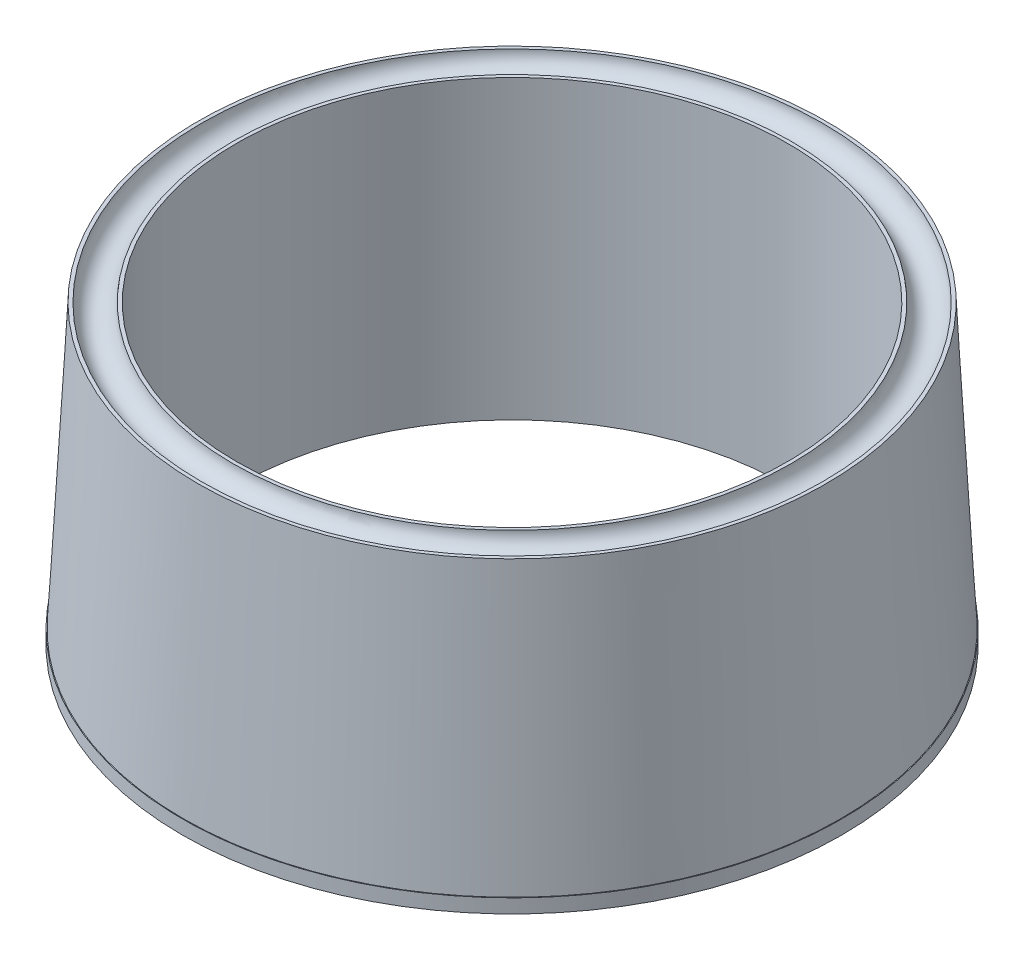
from build123d import *

# Parameters (mm, degrees)
SKETCH1_R            = 45
BOSS_EXTRUDE1_DEPTH  = 42.5
SKETCH2_R            = 39.5
CUT_EXTRUDE1_DEPTH   = 148
DRAFT2_ANGLE         = 3
CUT_EXTRUDE2_DEPTH   = 5
SKETCH7_R            = 47.22733062
BOSS_EXTRUDE2_DEPTH  = 2
SKETCH8_R            = 39.5
CUT_EXTRUDE3_DEPTH   = 66
CUT_EXTRUDE4_DEPTH   = 15
CUT_SWEEP1_PROFILE_R = 2.25


with BuildPart() as part:
    # Sketch1 → Boss-Extrude1 (new body)
    with BuildSketch(Plane(origin=(0, 0, 0), x_dir=(1, 0, 0), z_dir=(0, 1, 0))):
        Circle(SKETCH1_R)
    extrude(amount=BOSS_EXTRUDE1_DEPTH)

    # Sketch2 → Cut-Extrude1 (cut)
    with BuildSketch(Plane(origin=(0, 42.5, 0), x_dir=(1, 0, 0), z_dir=(0, 1, 0))):
        Circle(SKETCH2_R)
    extrude(amount=-CUT_EXTRUDE1_DEPTH, mode=Mode.SUBTRACT)

    # Draft2
    draft2_faces = [part.faces().sort_by_distance(p)[0] for p in [
        (-45, 21.25, 0),
    ]]
    draft(draft2_faces, Plane.ZX.offset(42.5), DRAFT2_ANGLE)

    # Sketch6 → Cut-Extrude2 (cut)
    with BuildSketch(Plane.XZ):
        Polygon((-24.581832655, 35.879719979), (-23.131832655, 35.042562088), (-21.681832655, 37.554035759), (-18.781832655, 37.554035759), (-18.781832655, 39.22835154), (-21.681832655, 40.902667321), (-24.581832655, 39.22835154), align=None)
        Polygon((18.781832655, 39.22835154), (18.781832655, 37.554035759), (21.681832655, 37.554035759), (23.131832655, 35.042562088), (24.581832655, 35.879719979), (24.581832655, 39.22835154), (21.681832655, 40.902667321), align=None)
        Polygon((43.36366531, 0), (41.91366531, -2.511473671), (43.36366531, -3.348631561), (46.26366531, -1.674315781), (46.26366531, 1.674315781), (43.36366531, 3.348631561), (41.91366531, 2.511473671), align=None)
        Polygon((21.681832655, -37.554035759), (18.781832655, -37.554035759), (18.781832655, -39.22835154), (21.681832655, -40.902667321), (24.581832655, -39.22835154), (24.581832655, -35.879719979), (23.131832655, -35.042562088), align=None)
        Polygon((-21.681832655, -37.554035759), (-23.131832655, -35.042562088), (-24.581832655, -35.879719979), (-24.581832655, -39.22835154), (-21.681832655, -40.902667321), (-18.781832655, -39.22835154), (-18.781832655, -37.554035759), align=None)
        Polygon((-41.91366531, -2.511473671), (-43.36366531, 0), (-41.91366531, 2.511473671), (-43.36366531, 3.348631561), (-46.26366531, 1.674315781), (-46.26366531, -1.674315781), (-43.36366531, -3.348631561), align=None)
        Polygon((-41.91366531, 2.511473671), (-43.36366531, 0), (-41.91366531, -2.511473671), (-40.46366531, -1.674315781), (-40.46366531, 1.674315781), align=None)
        Polygon((-21.681832655, 37.554035759), (-23.131832655, 35.042562088), (-21.681832655, 34.205404198), (-18.781832655, 35.879719979), (-18.781832655, 37.554035759), align=None)
        Polygon((21.681832655, 37.554035759), (18.781832655, 37.554035759), (18.781832655, 35.879719979), (21.681832655, 34.205404198), (23.131832655, 35.042562088), align=None)
        Polygon((40.46366531, -1.674315781), (41.91366531, -2.511473671), (43.36366531, 0), (41.91366531, 2.511473671), (40.46366531, 1.674315781), align=None)
        Polygon((18.781832655, -35.879719979), (18.781832655, -37.554035759), (21.681832655, -37.554035759), (23.131832655, -35.042562088), (21.681832655, -34.205404198), align=None)
        Polygon((-21.681832655, -34.205404198), (-23.131832655, -35.042562088), (-21.681832655, -37.554035759), (-18.781832655, -37.554035759), (-18.781832655, -35.879719979), align=None)
    extrude(amount=-CUT_EXTRUDE2_DEPTH, mode=Mode.SUBTRACT)

    # Sketch7 → Boss-Extrude2 (add)
    with BuildSketch(Plane.XZ):
        Circle(SKETCH7_R)
    extrude(amount=-BOSS_EXTRUDE2_DEPTH)

    # Sketch8 → Cut-Extrude3 (cut)
    with BuildSketch(Plane(origin=(0, 2, 0), x_dir=(1, 0, 0), z_dir=(0, 1, 0))):
        Circle(SKETCH8_R)
    extrude(amount=-CUT_EXTRUDE3_DEPTH, mode=Mode.SUBTRACT)

    # Sketch9 → Cut-Extrude4 (cut)
    with BuildSketch(Plane.XZ):
        with BuildLine():
            Line((-42.51, 1.472243186), (-43.36, 0))
            Line((-43.36, 0), (-42.51, -1.472243186))
            ThreePointArc((-42.51, -1.472243186), (-41.887756814, -0.85), (-41.66, 0))
            ThreePointArc((-41.66, 0), (-41.887756814, 0.85), (-42.51, 1.472243186))
        make_face()
        with BuildLine():
            Line((-42.51, -1.472243186), (-43.36, 0))
            Line((-43.36, 0), (-42.51, 1.472243186))
            ThreePointArc((-42.51, 1.472243186), (-45.06, 0), (-42.51, -1.472243186))
        make_face()
        with BuildLine():
            ThreePointArc((-19.98, 37.550861508), (-22.53, 39.023104695), (-22.53, 36.078618322))
            Line((-22.53, 36.078618322), (-21.68, 37.550861508))
            Line((-21.68, 37.550861508), (-19.98, 37.550861508))
        make_face()
        with BuildLine():
            Line((-21.68, 37.550861508), (-22.53, 36.078618322))
            ThreePointArc((-22.53, 36.078618322), (-20.83, 36.078618322), (-19.98, 37.550861508))
            Line((-19.98, 37.550861508), (-21.68, 37.550861508))
        make_face()
        with BuildLine():
            ThreePointArc((23.38, 37.550861508), (21.68, 39.250861508), (19.98, 37.550861508))
            Line((19.98, 37.550861508), (21.68, 37.550861508))
            Line((21.68, 37.550861508), (22.53, 36.078618322))
            ThreePointArc((22.53, 36.078618322), (23.152243186, 36.700861508), (23.38, 37.550861508))
        make_face()
        with BuildLine():
            Line((21.68, 37.550861508), (19.98, 37.550861508))
            ThreePointArc((19.98, 37.550861508), (20.83, 36.078618322), (22.53, 36.078618322))
            Line((22.53, 36.078618322), (21.68, 37.550861508))
        make_face()
        with BuildLine():
            ThreePointArc((42.51, 1.472243186), (41.66, 0), (42.51, -1.472243186))
            Line((42.51, -1.472243186), (43.36, 0))
            Line((43.36, 0), (42.51, 1.472243186))
        make_face()
        with BuildLine():
            Line((43.36, 0), (42.51, -1.472243186))
            ThreePointArc((42.51, -1.472243186), (44.21, -1.472243186), (45.06, 0))
            ThreePointArc((45.06, 0), (44.21, 1.472243186), (42.51, 1.472243186))
            Line((42.51, 1.472243186), (43.36, 0))
        make_face()
        with BuildLine():
            ThreePointArc((22.53, -36.078618322), (20.83, -36.078618322), (19.98, -37.550861508))
            Line((19.98, -37.550861508), (21.68, -37.550861508))
            Line((21.68, -37.550861508), (22.53, -36.078618322))
        make_face()
        with BuildLine():
            Line((21.68, -37.550861508), (19.98, -37.550861508))
            ThreePointArc((19.98, -37.550861508), (21.68, -39.250861508), (23.38, -37.550861508))
            ThreePointArc((23.38, -37.550861508), (23.152243186, -36.700861508), (22.53, -36.078618322))
            Line((22.53, -36.078618322), (21.68, -37.550861508))
        make_face()
        with BuildLine():
            ThreePointArc((-19.98, -37.550861508), (-20.83, -36.078618322), (-22.53, -36.078618322))
            Line((-22.53, -36.078618322), (-21.68, -37.550861508))
            Line((-21.68, -37.550861508), (-19.98, -37.550861508))
        make_face()
        with BuildLine():
            Line((-21.68, -37.550861508), (-22.53, -36.078618322))
            ThreePointArc((-22.53, -36.078618322), (-22.53, -39.023104695), (-19.98, -37.550861508))
            Line((-19.98, -37.550861508), (-21.68, -37.550861508))
        make_face()
    extrude(amount=-CUT_EXTRUDE4_DEPTH, mode=Mode.SUBTRACT)

    # Cut-Sweep1: sweep along a path in Sketch10
    with BuildLine(Plane(origin=(0, 42.5, 0), x_dir=(1, 0, 0), z_dir=(0, 1, 0))) as cut_sweep1_path:
        CenterArc((0, 0), 42.25, 0, 360)
    # Cut-Sweep1 profile (on start of the path) → Cut-Sweep1 (sweep, cut)
    with BuildSketch(Plane(origin=(42.25, 42.5, 0), x_dir=(-1, 0, 0), z_dir=(0, 0, -1))):
        Circle(CUT_SWEEP1_PROFILE_R)
    sweep(path=cut_sweep1_path.line, mode=Mode.SUBTRACT)


solid = part.part
